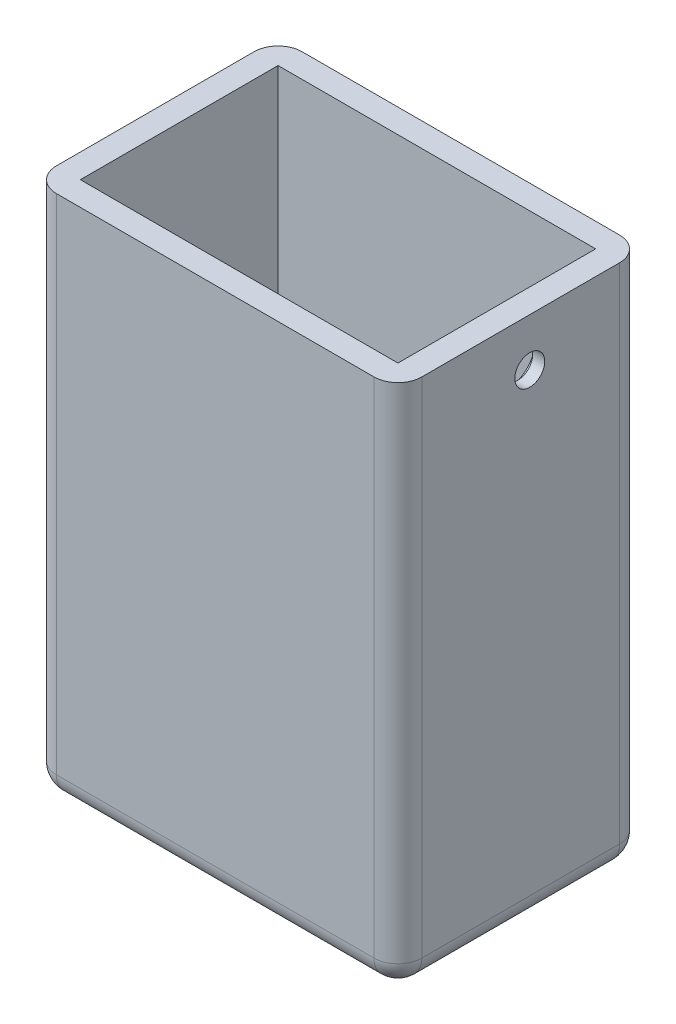
from build123d import *

# Parameters (mm, degrees)
ESBO_O1_W                = 61
ESBO_O1_H                = 92
ESBO_O1_W_2              = 53
ESBO_O1_H_2              = 84
RESSALTO_EXTRUS_O2_DEPTH = 33
ESBO_O5_W                = 61
ESBO_O5_H                = 92
RESSALTO_EXTRUS_O4_DEPTH = 4
ESBO_O6_R                = 2.5
CORTE_EXTRUS_O4_DEPTH    = 4
CORTE_EXTRUS_O5_DEPTH    = 2
ESBO_O8_W                = 61
ESBO_O8_H                = 92
RESSALTO_EXTRUS_O5_DEPTH = 4
ESBO_O9_W                = 61
ESBO_O9_H                = 41
CORTE_EXTRUS_O6_DEPTH    = 4
FILETE1_R                = 4


with BuildPart() as part:
    # Esboço1 → Ressalto-extrusão2 (new body)
    with BuildSketch(Plane.XY):
        with Locations((-12.234044221, -22.462857143)):
            Rectangle(ESBO_O1_W, ESBO_O1_H)
        with Locations((-12.234044221, -22.462857143)):
            Rectangle(ESBO_O1_W_2, ESBO_O1_H_2, mode=Mode.SUBTRACT)
    extrude(amount=-RESSALTO_EXTRUS_O2_DEPTH)

    # Esboço5 → Ressalto-extrusão4 (add)
    with BuildSketch(Plane.XY):
        with Locations((-12.234044221, -22.462857143)):
            Rectangle(ESBO_O5_W, ESBO_O5_H)
    extrude(amount=RESSALTO_EXTRUS_O4_DEPTH)

    # Esboço6 → Corte-extrusão4 (cut)
    with BuildSketch(Plane(origin=(18.265955779, 0, 0), x_dir=(0, 0, -1), z_dir=(1, 0, 0))):
        with Locations((18, 11.537142857)):
            Circle(ESBO_O6_R)
    extrude(amount=-CORTE_EXTRUS_O4_DEPTH, mode=Mode.SUBTRACT)

    # Esboço7 → Corte-extrusão5 (cut)
    with BuildSketch(Plane.ZY.offset(-14.265955779)):
        with BuildLine():
            Line((-11.1, 10.287142857), (-13.081921107, 10.287142857))
            ThreePointArc((-13.081921107, 10.287142857), (-13.142555013, 10.26666348), (-13.178354026, 10.213613445))
            ThreePointArc((-13.178354026, 10.213613445), (-18, 6.537142857), (-22.821645974, 10.213613445))
            ThreePointArc((-22.821645974, 10.213613445), (-22.857444987, 10.26666348), (-22.918078893, 10.287142857))
            Line((-22.918078893, 10.287142857), (-24.9, 10.287142857))
            ThreePointArc((-24.9, 10.287142857), (-24.970710678, 10.316432179), (-25, 10.387142857))
            Line((-25, 10.387142857), (-25, 12.687142857))
            ThreePointArc((-25, 12.687142857), (-24.970710678, 12.757853535), (-24.9, 12.787142857))
            Line((-24.9, 12.787142857), (-22.918078893, 12.787142857))
            ThreePointArc((-22.918078893, 12.787142857), (-22.857444987, 12.807622235), (-22.821645974, 12.860672269))
            ThreePointArc((-22.821645974, 12.860672269), (-18, 16.537142857), (-13.178354026, 12.860672269))
            ThreePointArc((-13.178354026, 12.860672269), (-13.142555013, 12.807622235), (-13.081921107, 12.787142857))
            Line((-13.081921107, 12.787142857), (-11.1, 12.787142857))
            ThreePointArc((-11.1, 12.787142857), (-11.029289322, 12.757853535), (-11, 12.687142857))
            Line((-11, 12.687142857), (-11, 10.387142857))
            ThreePointArc((-11, 10.387142857), (-11.029289322, 10.316432179), (-11.1, 10.287142857))
        make_face()
    extrude(amount=-CORTE_EXTRUS_O5_DEPTH, mode=Mode.SUBTRACT)

    # Esboço8 → Ressalto-extrusão5 (add)
    with BuildSketch(Plane(origin=(0, 0, -33), x_dir=(-1, 0, 0), z_dir=(0, 0, -1))):
        with Locations((12.234044221, -22.462857143)):
            Rectangle(ESBO_O8_W, ESBO_O8_H)
    extrude(amount=RESSALTO_EXTRUS_O5_DEPTH)

    # Esboço9 → Corte-extrusão6 (cut)
    with BuildSketch(Plane(origin=(0, 23.537142857, 0), x_dir=(1, 0, 0), z_dir=(0, 1, 0))):
        with Locations((-12.234044221, 16.5)):
            Rectangle(ESBO_O9_W, ESBO_O9_H)
    extrude(amount=-CORTE_EXTRUS_O6_DEPTH, mode=Mode.SUBTRACT)

    # Filete1
    filete1_edges = [part.edges().sort_by_distance(p)[0] for p in [
        (18.265955779, -24.462857143, -37),
        (-42.734044221, -24.462857143, 4),
        (-12.234044221, -68.462857143, 4),
        (18.265955779, -24.462857143, 4),
        (18.265955779, -68.462857143, -16.5),
        (-42.734044221, -68.462857143, -16.5),
        (-12.234044221, -68.462857143, -37),
        (-42.734044221, -24.462857143, -37),
    ]]
    fillet(filete1_edges, radius=FILETE1_R)


solid = part.part
